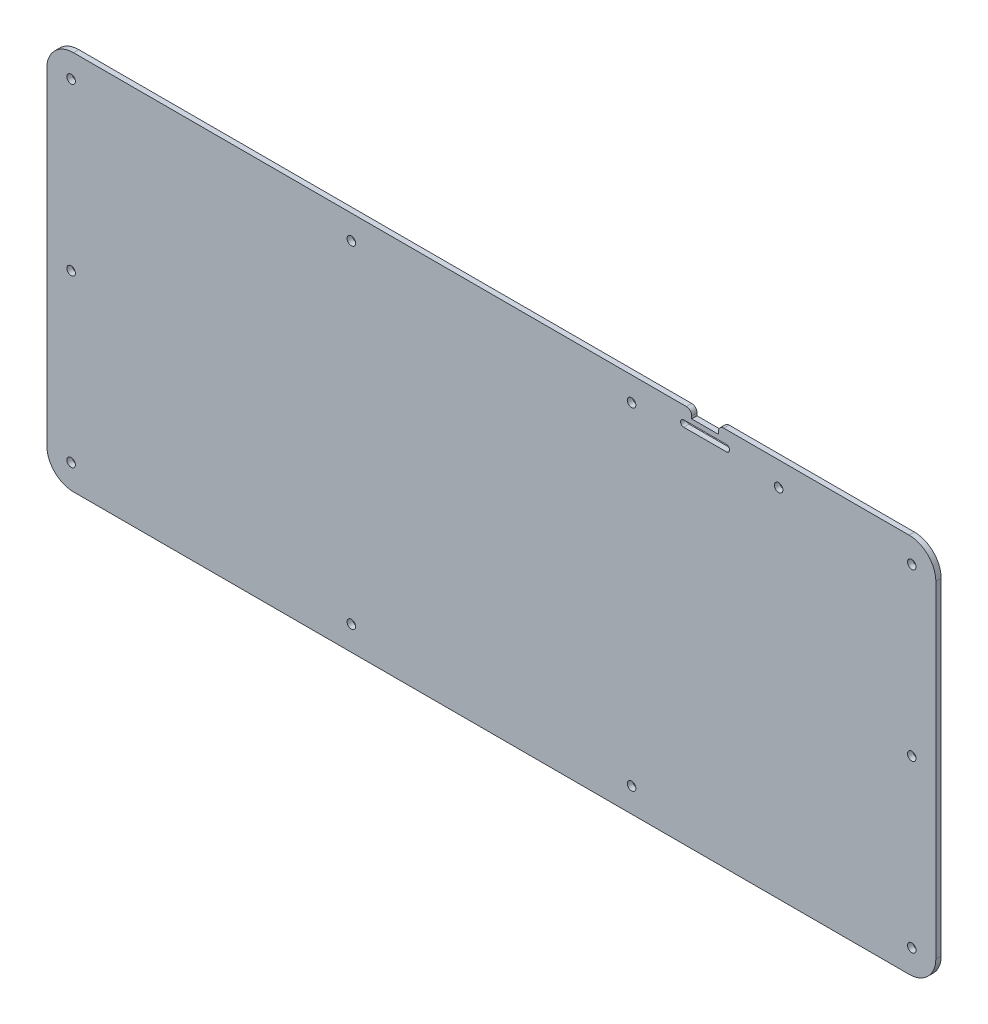
from build123d import *

# Parameters (mm, degrees)
SKETCH_1_R      = 1.6
SKETCH_1_R_2    = 1.5998
SKETCH_1_R_3    = 1.59992
EXTRUDE_2_DEPTH = 2


with BuildPart() as part:
    # 草图1 → 凸台-拉伸2 (new body)
    with BuildSketch(Plane.XY):
        with BuildLine():
            Line((-165.158505018, 77.433579777), (-165.158505018, -44.999420223))
            ThreePointArc((-165.158505018, -44.999420223), (-162.22957283, -52.070488035), (-155.158505018, -54.999420223))
            Line((-155.158505018, -54.999420223), (157.738494982, -54.999420223))
            ThreePointArc((157.738494982, -54.999420223), (164.809562794, -52.070488035), (167.738494982, -44.999420223))
            Line((167.738494982, -44.999420223), (167.738494982, 77.433579777))
            ThreePointArc((167.738494982, 77.433579777), (164.809562794, 84.504647589), (157.738494982, 87.433579777))
            Line((157.738494982, 87.433579777), (88.337494982, 87.433579777))
            ThreePointArc((88.337494982, 87.433579777), (86.92328142, 86.847793339), (86.337494982, 85.433579777))
            Line((86.337494982, 85.433579777), (86.337494982, 84.433579777))
            Line((86.337494982, 84.433579777), (76.337494982, 84.433579777))
            Line((76.337494982, 84.433579777), (76.337494982, 85.433579777))
            ThreePointArc((76.337494982, 85.433579777), (75.751708545, 86.847793339), (74.337494982, 87.433579777))
            Line((74.337494982, 87.433579777), (-155.158505018, 87.433579777))
            ThreePointArc((-155.158505018, 87.433579777), (-162.22957283, 84.504647589), (-165.158505018, 77.433579777))
        make_face()
        with Locations((53.803494982, 78.433579777)):
            Circle(SKETCH_1_R, mode=Mode.SUBTRACT)
        with Locations((108.871494982, 78.433579777)):
            Circle(SKETCH_1_R, mode=Mode.SUBTRACT)
        with Locations((158.738494982, 78.433579777)):
            Circle(SKETCH_1_R, mode=Mode.SUBTRACT)
        with Locations((158.738494982, 16.282479777)):
            Circle(SKETCH_1_R_2, mode=Mode.SUBTRACT)
        with Locations((158.738494982, -45.868520223)):
            Circle(SKETCH_1_R_3, mode=Mode.SUBTRACT)
        with Locations((53.803494982, -45.868520223)):
            Circle(SKETCH_1_R_3, mode=Mode.SUBTRACT)
        with Locations((-51.129505018, -45.868520223)):
            Circle(SKETCH_1_R_3, mode=Mode.SUBTRACT)
        with Locations((-156.063435018, -45.868520223)):
            Circle(SKETCH_1_R_3, mode=Mode.SUBTRACT)
        with Locations((-156.063435018, 16.282479777)):
            Circle(SKETCH_1_R_2, mode=Mode.SUBTRACT)
        with Locations((-156.063435018, 78.433579777)):
            Circle(SKETCH_1_R, mode=Mode.SUBTRACT)
        with Locations((-51.129505018, 78.433579777)):
            Circle(SKETCH_1_R, mode=Mode.SUBTRACT)
        with BuildLine():
            Line((73.337494982, 82.633579777), (89.337494982, 82.633579777))
            ThreePointArc((89.337494982, 82.633579777), (90.537494982, 81.433579777), (89.337494982, 80.233579777))
            Line((89.337494982, 80.233579777), (73.337494982, 80.233579777))
            ThreePointArc((73.337494982, 80.233579777), (72.137494982, 81.433579777), (73.337494982, 82.633579777))
        make_face(mode=Mode.SUBTRACT)
    extrude(amount=EXTRUDE_2_DEPTH)


solid = part.part
